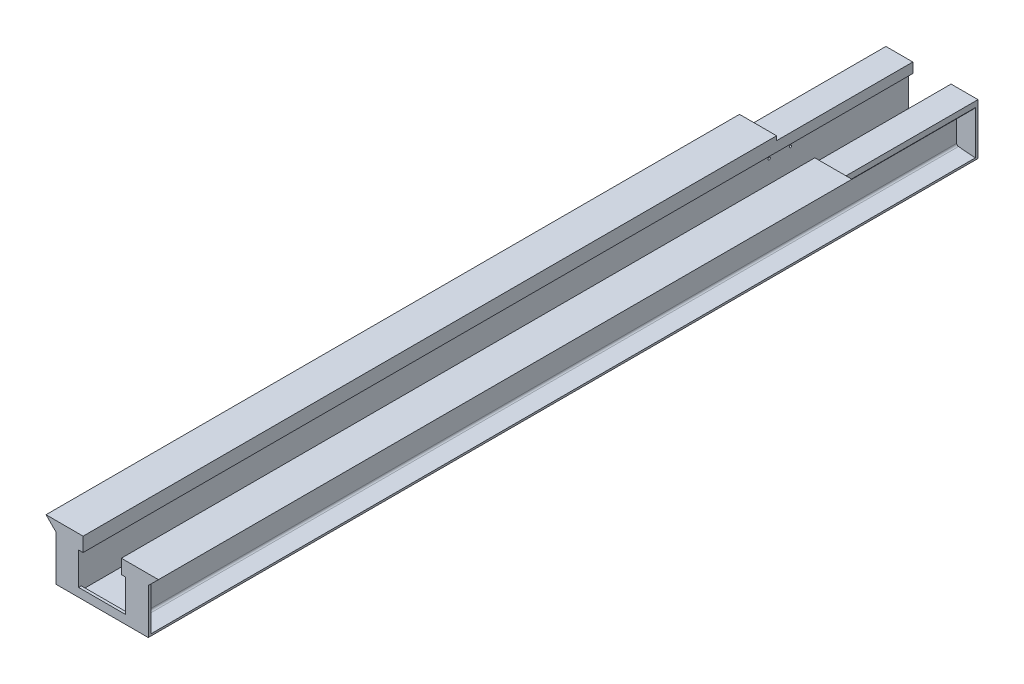
from build123d import *

# Parameters (mm, degrees)
DODANIE_WYCI_GNI_CIE1_DEPTH = 1800
DODANIE_WYCI_GNI_CIE2_DEPTH = 348
DODANIE_WYCI_GNI_CIE3_DEPTH = 7
DODANIE_WYCI_GNI_CIE5_DEPTH = 7
ZAOKR_GLENIE1_R             = 5
SZKIC16_R                   = 3
WYTNIJ_WYCI_GNI_CIE1_DEPTH  = 10.2


with BuildPart() as part:
    # Szkic4 → Dodanie-wyciągnięcie1 (new body)
    with BuildSketch(Plane.XY):
        Polygon((0, 0), (0, 5), (48.5, 9), (48.5, 107), (6.5, 111), (-26.5, 144), (70.2, 144), (70.2, 107), (58.679571348, 107), (58.679571348, 13), (181.3, 13), (181.3, 107), (169.8, 107), (169.8, 144), (266.5, 144), (233.5, 111), (191.5, 107), (191.5, 9), (240, 5), (240, 0), align=None)
    extrude(amount=DODANIE_WYCI_GNI_CIE1_DEPTH)

    # Szkic5 → Dodanie-wyciągnięcie2 (add)
    with BuildSketch(Plane.XY):
        Polygon((0, 0), (0, 5), (48.5, 9), (48.5, 107), (6.5, 111), (0, 117.5), (0, 133), (6.5, 133), (70.2, 133), (70.2, 107), (58.679571348, 107), (58.679571348, 13), (181.3, 13), (181.3, 107), (169.8, 107), (169.8, 133), (233.5, 133), (240, 133), (240, 118.39460416), (233.5, 111), (191.5, 107), (191.5, 9), (240, 5), (240, 0), align=None)
    extrude(amount=-DODANIE_WYCI_GNI_CIE2_DEPTH)

    # Szkic10 → Dodanie-wyciągnięcie3 (add)
    with BuildSketch(Plane.XY.offset(-348)):
        Polygon((0, 0), (0, 117.5), (0, 133), (6.5, 133), (70.2, 133), (70.2, 107), (58.679571348, 107), (58.679571348, 22.5), (181.3, 22.5), (181.3, 107), (169.8, 107), (169.8, 133), (233.5, 133), (240, 133), (240, 118.39460416), (240, 0), align=None)
    extrude(amount=-DODANIE_WYCI_GNI_CIE3_DEPTH)

    # Szkic11 → Dodanie-wyciągnięcie5 (add)
    with BuildSketch(Plane.XY.offset(1800)):
        Polygon((0, 0), (0, 5), (0, 117.5), (-26.5, 144), (70.2, 144), (70.2, 107), (58.679571348, 107), (58.679571348, 22.5), (181.3, 22.5), (181.3, 107), (169.8, 107), (169.8, 144), (266.5, 144), (240, 117.5), (240, 5), (240, 0), align=None)
    extrude(amount=DODANIE_WYCI_GNI_CIE5_DEPTH)

    # Zaokrąglenie1
    zaokr_glenie1_edges = [part.edges().sort_by_distance(p)[0] for p in [
        (48.5, 107, 726),
        (48.5, 9, 726),
        (191.5, 9, 726),
        (191.5, 107, 726),
    ]]
    fillet(zaokr_glenie1_edges, radius=ZAOKR_GLENIE1_R)

    # Szkic16 → Wytnij-wyciągnięcie1 (cut)
    with BuildSketch(Plane.ZY.offset(-48.5)):
        with Locations((-48, 90.453565926)):
            Circle(SZKIC16_R)
        with Locations((7.7, 90.453565926)):
            Circle(SZKIC16_R)
        with Locations((7.7, 24.453565926)):
            Circle(SZKIC16_R)
        with Locations((-48, 24.453565926)):
            Circle(SZKIC16_R)
    extrude(amount=-WYTNIJ_WYCI_GNI_CIE1_DEPTH, mode=Mode.SUBTRACT)


solid = part.part
